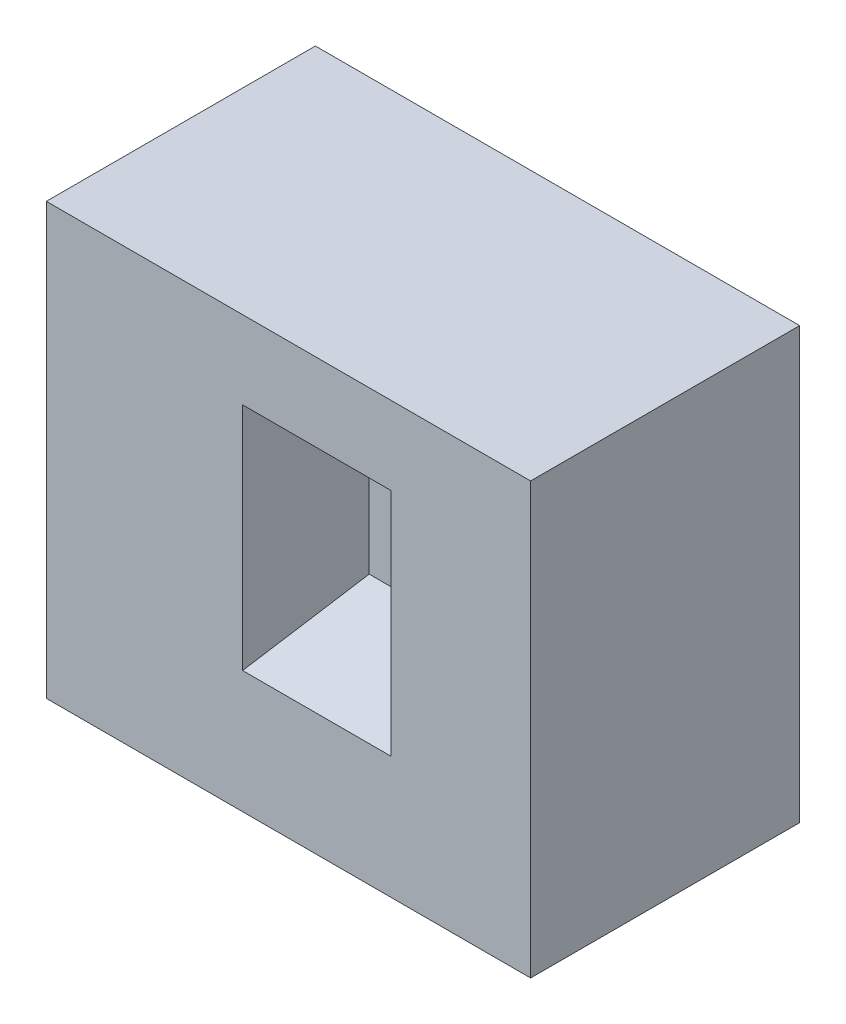
from build123d import *

# Parameters (mm, degrees)
SKETCH1_W     = 90
SKETCH1_H     = 80
BASE_DEPTH    = 25
SKETCH2_W     = 12.505871318
SKETCH2_H     = 18.704284341
POCKET_DEPTH  = 20
DRAFT10_ANGLE = 10
DRAFT20_ANGLE = 20
DRAFT30_ANGLE = 30
DRAFT40_ANGLE = 40


with BuildPart() as part:
    # Sketch1 → Base (new body, symmetric)
    with BuildSketch(Plane.XY):
        with Locations((45, 40)):
            Rectangle(SKETCH1_W, SKETCH1_H)
    extrude(amount=BASE_DEPTH, both=True)

    # Sketch2 → Pocket (cut)
    with BuildSketch(Plane.XY.offset(25)):
        with Locations((46.252935659, 39.352142171)):
            Rectangle(SKETCH2_W, SKETCH2_H)
    extrude(amount=-POCKET_DEPTH, mode=Mode.SUBTRACT)

    # Draft10
    draft10_faces = [part.faces().sort_by_distance(p)[0] for p in [
        (40, 39.35214217, 15),
    ]]
    draft(draft10_faces, Plane(origin=(40, 48.704284341, 5), x_dir=(1, 0, 0), z_dir=(0, 0, 1)), DRAFT10_ANGLE)

    # Draft20
    draft20_faces = [part.faces().sort_by_distance(p)[0] for p in [
        (45.334985554, 30, 15.411907484),
    ]]
    draft(draft20_faces, Plane(origin=(40, 48.704284341, 5), x_dir=(1, 0, 0), z_dir=(0, 0, 1)), DRAFT20_ANGLE)

    # Draft30
    draft30_faces = [part.faces().sort_by_distance(p)[0] for p in [
        (52.505871318, 37.433476694, 15.542980146),
    ]]
    draft(draft30_faces, Plane(origin=(40, 48.704284341, 5), x_dir=(1, 0, 0), z_dir=(0, 0, 1)), DRAFT30_ANGLE)

    # Draft40
    draft40_faces = [part.faces().sort_by_distance(p)[0] for p in [
        (48.509384653, 48.704284341, 16.253456142),
    ]]
    draft(draft40_faces, Plane(origin=(40, 48.704284341, 5), x_dir=(1, 0, 0), z_dir=(0, 0, 1)), DRAFT40_ANGLE)


solid = part.part
